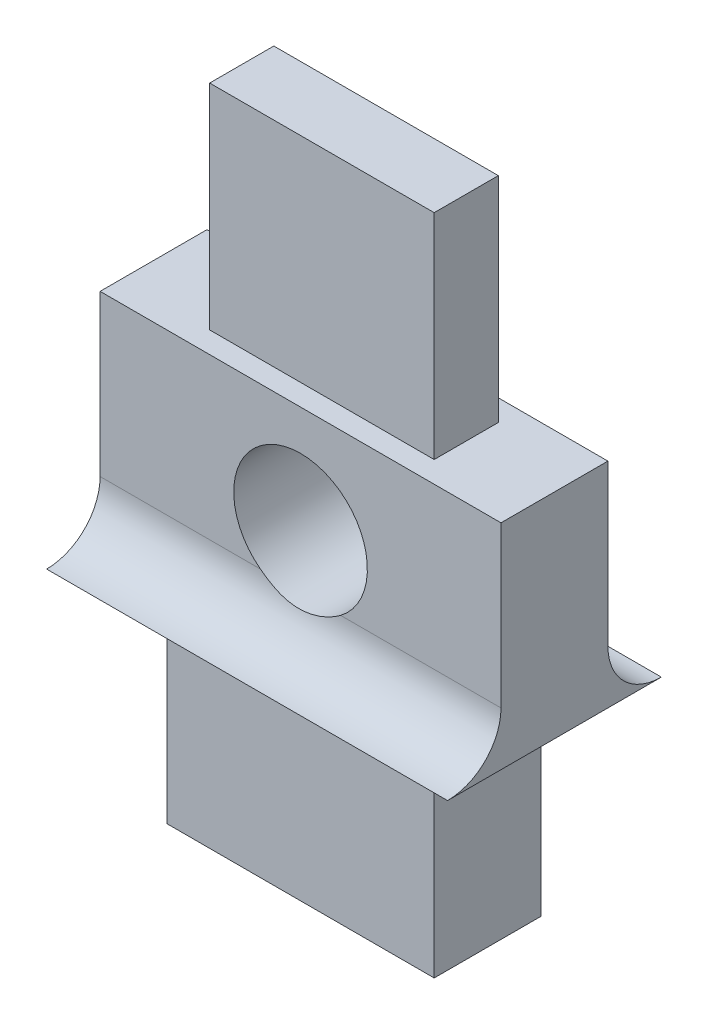
from build123d import *

# Parameters (mm, degrees)
SKETCH1_R               = 1.25
BOSS_EXTRUDE1_DEPTH     = 2
BOSS_EXTRUDE2_DEPTH     = 7.5
SKETCH3_R               = 1.25
CUT_EXTRUDE1_DEPTH      = 2
CUT_EXTRUDE1_DEPTH_BACK = 4
SKETCH4_W               = 5
SKETCH4_H               = 2
SKETCH4_W_2             = 4.2
SKETCH4_H_2             = 1.2
CUT_EXTRUDE2_DEPTH      = 4


with BuildPart() as part:
    # Sketch1 → Boss-Extrude1 (new body)
    with BuildSketch(Plane.XY):
        Polygon((1952.176808721, 1466.884115951), (1957.176808721, 1466.884115951), (1957.176808721, 1462.884115951), (1958.426808721, 1462.884115951), (1958.426808721, 1458.884115951), (1957.176808721, 1458.884115951), (1957.176808721, 1454.884115951), (1952.176808721, 1454.884115951), (1952.176808721, 1458.884115951), (1950.926808721, 1458.884115951), (1950.926808721, 1462.884115951), (1952.176808721, 1462.884115951), align=None)
        with Locations((1954.676808721, 1460.884115951)):
            Circle(SKETCH1_R, mode=Mode.SUBTRACT)
    extrude(amount=BOSS_EXTRUDE1_DEPTH)

    # Sketch2 → Boss-Extrude2 (add)
    with BuildSketch(Plane.ZY.offset(-1950.926808721)):
        with BuildLine():
            Line((2, 1458.884115951), (2, 1459.884115951))
            ThreePointArc((2, 1459.884115951), (2.292893219, 1459.17700917), (3, 1458.884115951))
            Line((3, 1458.884115951), (2, 1458.884115951))
        make_face()
        with BuildLine():
            Line((0, 1458.884115951), (-1, 1458.884115951))
            ThreePointArc((-1, 1458.884115951), (-0.292893219, 1459.17700917), (0, 1459.884115951))
            Line((0, 1459.884115951), (0, 1458.884115951))
        make_face()
    extrude(amount=-BOSS_EXTRUDE2_DEPTH)

    # Sketch3 → Cut-Extrude1 (cut, two sides)
    with BuildSketch(Plane.XY.offset(2)) as cut_extrude1_sk:
        with Locations((1954.676808721, 1460.884115951)):
            Circle(SKETCH3_R)
    extrude(amount=CUT_EXTRUDE1_DEPTH, mode=Mode.SUBTRACT)
    extrude(cut_extrude1_sk.sketch, amount=-CUT_EXTRUDE1_DEPTH_BACK, mode=Mode.SUBTRACT)

    # Sketch4 → Cut-Extrude2 (cut)
    with BuildSketch(Plane(origin=(0, 1466.884115951, 0), x_dir=(1, 0, 0), z_dir=(0, 1, 0))):
        with Locations((1954.676808721, -1)):
            Rectangle(SKETCH4_W, SKETCH4_H)
        with Locations((1954.676808721, -1)):
            Rectangle(SKETCH4_W_2, SKETCH4_H_2, mode=Mode.SUBTRACT)
    extrude(amount=-CUT_EXTRUDE2_DEPTH, mode=Mode.SUBTRACT)


solid = part.part
